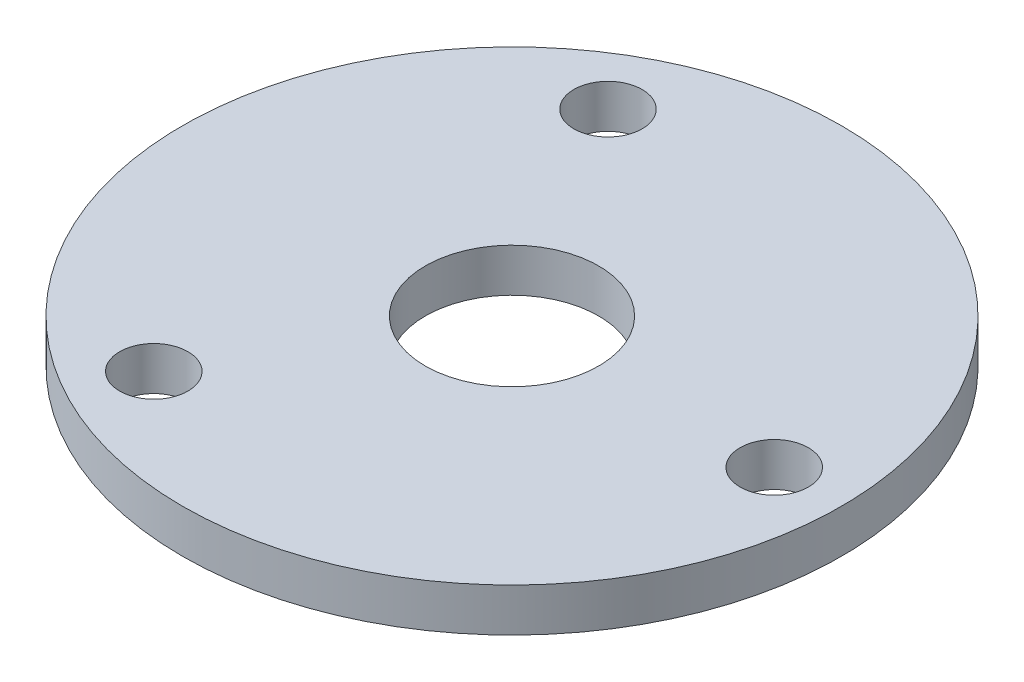
from build123d import *

# Parameters (mm, degrees)
SKETCH1_R           = 24.13
SKETCH1_R_2         = 2.5
SKETCH1_R_3         = 6.35
BOSS_EXTRUDE1_DEPTH = 3.175


with BuildPart() as part:
    # Sketch1 → Boss-Extrude1 (new body)
    with BuildSketch(Plane(origin=(0, 0, 0), x_dir=(1, 0, 0), z_dir=(0, 1, 0))):
        Circle(SKETCH1_R)
        with Locations((19.2, 0)):
            Circle(SKETCH1_R_2, mode=Mode.SUBTRACT)
        with Locations((-9.6, 16.627687753)):
            Circle(SKETCH1_R_2, mode=Mode.SUBTRACT)
        with Locations((-9.6, -16.627687753)):
            Circle(SKETCH1_R_2, mode=Mode.SUBTRACT)
        Circle(SKETCH1_R_3, mode=Mode.SUBTRACT)
    extrude(amount=BOSS_EXTRUDE1_DEPTH)


solid = part.part
